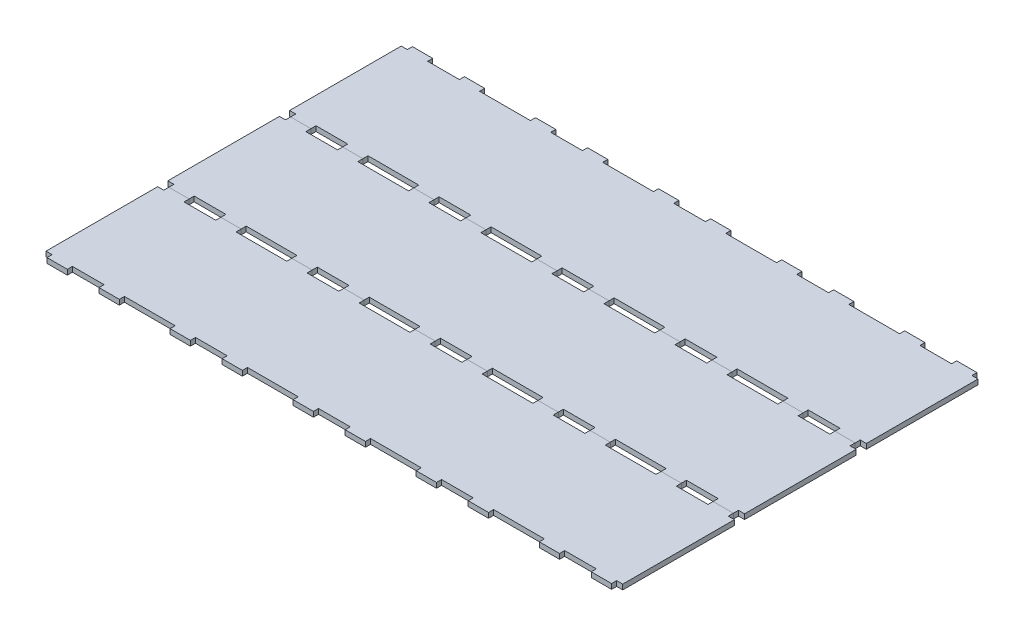
from build123d import *

# Parameters (mm, degrees)
SKETCH1_W                 = 721.63658441
SKETCH1_H                 = 152.4
BOSS_EXTRUDE1_DEPTH       = 6.35
SKETCH2_W                 = 39.679316882
SKETCH2_H                 = 6.35
SKETCH2_W_2               = 31.750000127
CUT_EXTRUDE1_DEPTH        = 7.35
LPATTERN1_COUNT           = 3
LPATTERN1_PITCH           = 153.979316882
LPATTERN1_COL_COUNT       = 3
LPATTERN1_COL_PITCH       = 153.979316882
MIRROR1_COPY_1_SKETCH_W   = 39.679316882
MIRROR1_COPY_1_SKETCH_H   = 6.35
MIRROR1_COPY_1_SKETCH_W_2 = 31.750000127
MIRROR1_COPY_1_DEPTH      = 7.35
MIRROR1_COPY_2_SKETCH_W   = 39.679316882
MIRROR1_COPY_2_SKETCH_H   = 6.35
MIRROR1_COPY_2_SKETCH_W_2 = 31.750000127
MIRROR1_COPY_2_DEPTH      = 7.35
MIRROR1_COPY_3_SKETCH_W   = 39.679316882
MIRROR1_COPY_3_SKETCH_H   = 6.35
MIRROR1_COPY_3_SKETCH_W_2 = 31.750000127
MIRROR1_COPY_3_DEPTH      = 7.35
MIRROR1_COPY_4_SKETCH_W   = 39.679316882
MIRROR1_COPY_4_SKETCH_H   = 6.35
MIRROR1_COPY_4_SKETCH_W_2 = 31.750000127
MIRROR1_COPY_4_DEPTH      = 7.35
LPATTERN2_COUNT           = 3
LPATTERN2_PITCH           = 152.4


with BuildPart() as part:
    # Sketch1 → Boss-Extrude1 (new body)
    with BuildSketch(Plane(origin=(0, 0, 0), x_dir=(1, 0, 0), z_dir=(0, 1, 0))):
        Rectangle(SKETCH1_W, SKETCH1_H)
    extrude(amount=BOSS_EXTRUDE1_DEPTH)

    # Sketch2 → Cut-Extrude1 (cut, through all)
    with BuildSketch(Plane(origin=(0, 6.35, 0), x_dir=(1, 0, 0), z_dir=(0, 1, 0))):
        with Locations((0, -73.025)):
            Rectangle(SKETCH2_W, SKETCH2_H)
        with Locations((-61.114658505, -73.025)):
            Rectangle(SKETCH2_W_2, SKETCH2_H)
        with Locations((61.114658505, -73.025)):
            Rectangle(SKETCH2_W_2, SKETCH2_H)
    cut_extrude1 = extrude(amount=-CUT_EXTRUDE1_DEPTH, mode=Mode.SUBTRACT)

    # LPattern1: Cut-Extrude1 ×3
    with Locations(*[(i * LPATTERN1_PITCH, 0, 0) for i in range(1, LPATTERN1_COUNT)]):
        add(cut_extrude1, mode=Mode.SUBTRACT)

    # LPattern1 col: Cut-Extrude1 ×3
    with Locations(*[(-i * LPATTERN1_COL_PITCH, 0, 0) for i in range(1, LPATTERN1_COL_COUNT)]):
        add(cut_extrude1, mode=Mode.SUBTRACT)

    # Mirror1: Cut-Extrude1 across plane
    add(cut_extrude1.mirror(Plane.XY), mode=Mode.SUBTRACT)

    # Mirror1 copy 1 sketch → Mirror1 copy 1 (cut, through all)
    with BuildSketch(Plane(origin=(153.979316882, 6.35, 0), x_dir=(1, 0, 0), z_dir=(0, 1, 0))):
        with Locations((0, 73.025)):
            Rectangle(MIRROR1_COPY_1_SKETCH_W, MIRROR1_COPY_1_SKETCH_H)
        with Locations((-61.114658505, 73.025)):
            Rectangle(MIRROR1_COPY_1_SKETCH_W_2, MIRROR1_COPY_1_SKETCH_H)
        with Locations((61.114658505, 73.025)):
            Rectangle(MIRROR1_COPY_1_SKETCH_W_2, MIRROR1_COPY_1_SKETCH_H)
    extrude(amount=-MIRROR1_COPY_1_DEPTH, mode=Mode.SUBTRACT)

    # Mirror1 copy 2 sketch → Mirror1 copy 2 (cut, through all)
    with BuildSketch(Plane(origin=(307.958633764, 6.35, 0), x_dir=(1, 0, 0), z_dir=(0, 1, 0))):
        with Locations((0, 73.025)):
            Rectangle(MIRROR1_COPY_2_SKETCH_W, MIRROR1_COPY_2_SKETCH_H)
        with Locations((-61.114658505, 73.025)):
            Rectangle(MIRROR1_COPY_2_SKETCH_W_2, MIRROR1_COPY_2_SKETCH_H)
        with Locations((61.114658505, 73.025)):
            Rectangle(MIRROR1_COPY_2_SKETCH_W_2, MIRROR1_COPY_2_SKETCH_H)
    extrude(amount=-MIRROR1_COPY_2_DEPTH, mode=Mode.SUBTRACT)

    # Mirror1 copy 3 sketch → Mirror1 copy 3 (cut, through all)
    with BuildSketch(Plane(origin=(-153.979316882, 6.35, 0), x_dir=(1, 0, 0), z_dir=(0, 1, 0))):
        with Locations((0, 73.025)):
            Rectangle(MIRROR1_COPY_3_SKETCH_W, MIRROR1_COPY_3_SKETCH_H)
        with Locations((-61.114658505, 73.025)):
            Rectangle(MIRROR1_COPY_3_SKETCH_W_2, MIRROR1_COPY_3_SKETCH_H)
        with Locations((61.114658505, 73.025)):
            Rectangle(MIRROR1_COPY_3_SKETCH_W_2, MIRROR1_COPY_3_SKETCH_H)
    extrude(amount=-MIRROR1_COPY_3_DEPTH, mode=Mode.SUBTRACT)

    # Mirror1 copy 4 sketch → Mirror1 copy 4 (cut, through all)
    with BuildSketch(Plane(origin=(-307.958633764, 6.35, 0), x_dir=(1, 0, 0), z_dir=(0, 1, 0))):
        with Locations((0, 73.025)):
            Rectangle(MIRROR1_COPY_4_SKETCH_W, MIRROR1_COPY_4_SKETCH_H)
        with Locations((-61.114658505, 73.025)):
            Rectangle(MIRROR1_COPY_4_SKETCH_W_2, MIRROR1_COPY_4_SKETCH_H)
        with Locations((61.114658505, 73.025)):
            Rectangle(MIRROR1_COPY_4_SKETCH_W_2, MIRROR1_COPY_4_SKETCH_H)
    extrude(amount=-MIRROR1_COPY_4_DEPTH, mode=Mode.SUBTRACT)


with BuildPart() as lpattern2_1:
    # LPattern2: pattern copy
    add(part.part.moved(Location(Vector(0, 0, 1) * (1 * LPATTERN2_PITCH))))


with BuildPart() as lpattern2_2:
    # LPattern2: pattern copy
    add(part.part.moved(Location(Vector(0, 0, 1) * (2 * LPATTERN2_PITCH))))


solid = Compound([part.part, lpattern2_1.part, lpattern2_2.part])
